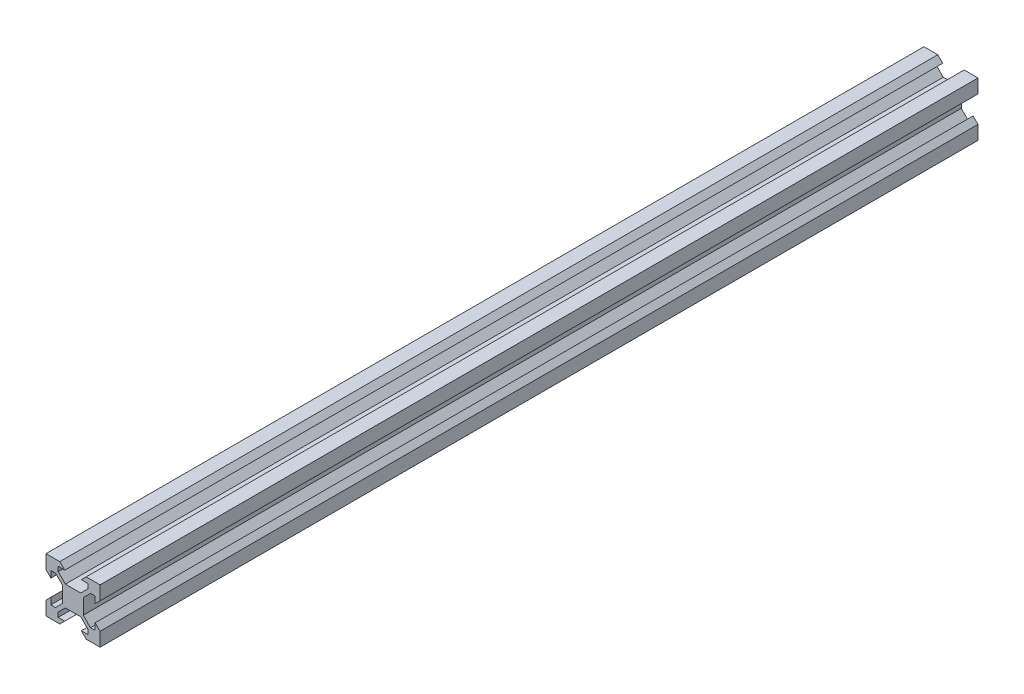
from build123d import *

# Parameters (mm, degrees)
SKETCH1_W           = 20
SKETCH1_H           = 20
BOSS_EXTRUDE1_DEPTH = 324.8
CUT_EXTRUDE1_DEPTH  = 325.8


with BuildPart() as part:
    # Sketch1 → Boss-Extrude1 (new body)
    with BuildSketch(Plane.XY):
        with Locations((10, 10)):
            Rectangle(SKETCH1_W, SKETCH1_H)
    extrude(amount=BOSS_EXTRUDE1_DEPTH)

    # Sketch2 → Cut-Extrude1 (cut, through all)
    with BuildSketch(Plane.XY.offset(324.8)):
        Polygon((4.5, 18.18), (6.94, 18.18), (5.12, 20), (14.88, 20), (13.06, 18.18), (15.5, 18.18), (15.5, 16.475807358), (12.834192642, 13.81), (7.165807358, 13.81), (4.5, 16.475807358), align=None)
        Polygon((14.88, 0), (13.06, 1.82), (15.5, 1.82), (15.5, 3.524192642), (12.834192642, 6.19), (7.165807358, 6.19), (4.5, 3.524192642), (4.5, 1.82), (6.94, 1.82), (5.12, 0), align=None)
        Polygon((1.82, 4.5), (1.82, 6.94), (0, 5.12), (0, 14.88), (1.82, 13.06), (1.82, 15.5), (3.524192642, 15.5), (6.19, 12.834192642), (6.19, 7.165807358), (3.524192642, 4.5), align=None)
        Polygon((20, 14.88), (18.18, 13.06), (18.18, 15.5), (16.475807358, 15.5), (13.81, 12.834192642), (13.81, 7.165807358), (16.475807358, 4.5), (18.18, 4.5), (18.18, 6.94), (20, 5.12), align=None)
    extrude(amount=-CUT_EXTRUDE1_DEPTH, mode=Mode.SUBTRACT)


solid = part.part
